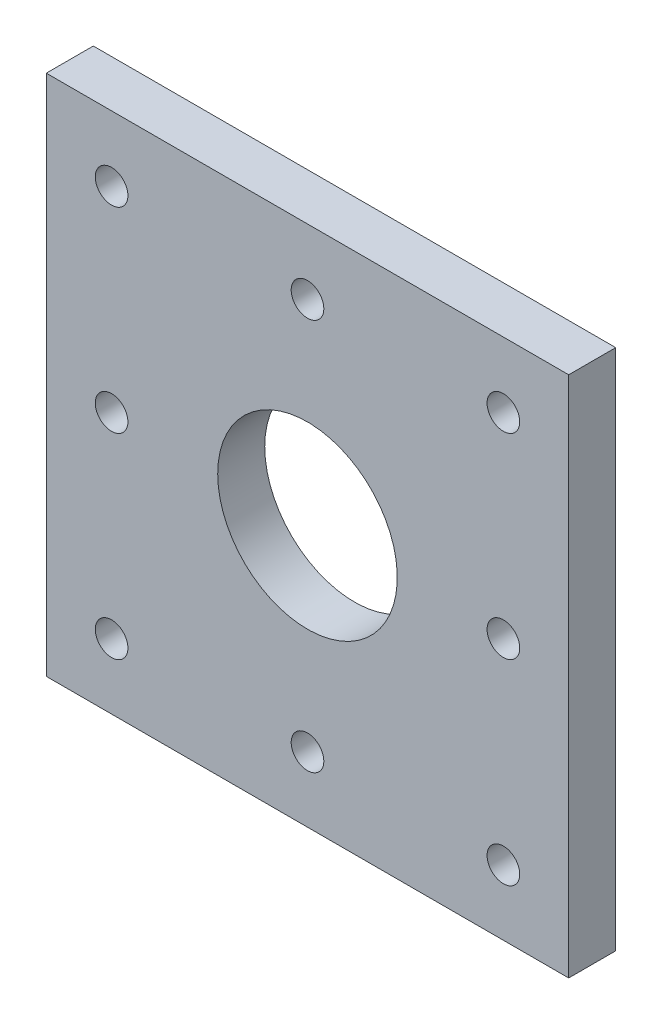
from build123d import *

# Parameters (mm, degrees)
SKETCH1_W           = 50.8
SKETCH1_H           = 50.8
BOSS_EXTRUDE1_DEPTH = 4.572
SKETCH2_R           = 8.73125
CUT_EXTRUDE7_DEPTH  = 5.572
SKETCH5_R           = 1.5875
CUT_EXTRUDE8_DEPTH  = 5.572
SKETCH7_R           = 1.5875
CUT_EXTRUDE9_DEPTH  = 5.572


with BuildPart() as part:
    # Sketch1 → Boss-Extrude1 (new body)
    with BuildSketch(Plane.XY):
        with Locations((25.4, 25.4)):
            Rectangle(SKETCH1_W, SKETCH1_H)
    extrude(amount=BOSS_EXTRUDE1_DEPTH)

    # Sketch2 → Cut-Extrude7 (cut, through all)
    with BuildSketch(Plane(origin=(0, 0, 0), x_dir=(-1, 0, 0), z_dir=(0, 0, -1))):
        with Locations((-25.4, 25.4)):
            Circle(SKETCH2_R)
    extrude(amount=-CUT_EXTRUDE7_DEPTH, mode=Mode.SUBTRACT)

    # Sketch5 → Cut-Extrude8 (cut, through all)
    with BuildSketch(Plane.XY.offset(4.572)):
        with Locations((25.4, 6.35)):
            Circle(SKETCH5_R)
        with Locations((6.35, 25.4)):
            Circle(SKETCH5_R)
        with Locations((25.4, 44.45)):
            Circle(SKETCH5_R)
        with Locations((44.45, 25.4)):
            Circle(SKETCH5_R)
    extrude(amount=-CUT_EXTRUDE8_DEPTH, mode=Mode.SUBTRACT)

    # Sketch7 → Cut-Extrude9 (cut, through all)
    with BuildSketch(Plane(origin=(0, 0, 0), x_dir=(-1, 0, 0), z_dir=(0, 0, -1))):
        with Locations((-6.35, 6.35)):
            Circle(SKETCH7_R)
        with Locations((-44.45, 6.35)):
            Circle(SKETCH7_R)
        with Locations((-44.45, 44.45)):
            Circle(SKETCH7_R)
        with Locations((-6.35, 44.45)):
            Circle(SKETCH7_R)
    extrude(amount=-CUT_EXTRUDE9_DEPTH, mode=Mode.SUBTRACT)


solid = part.part
